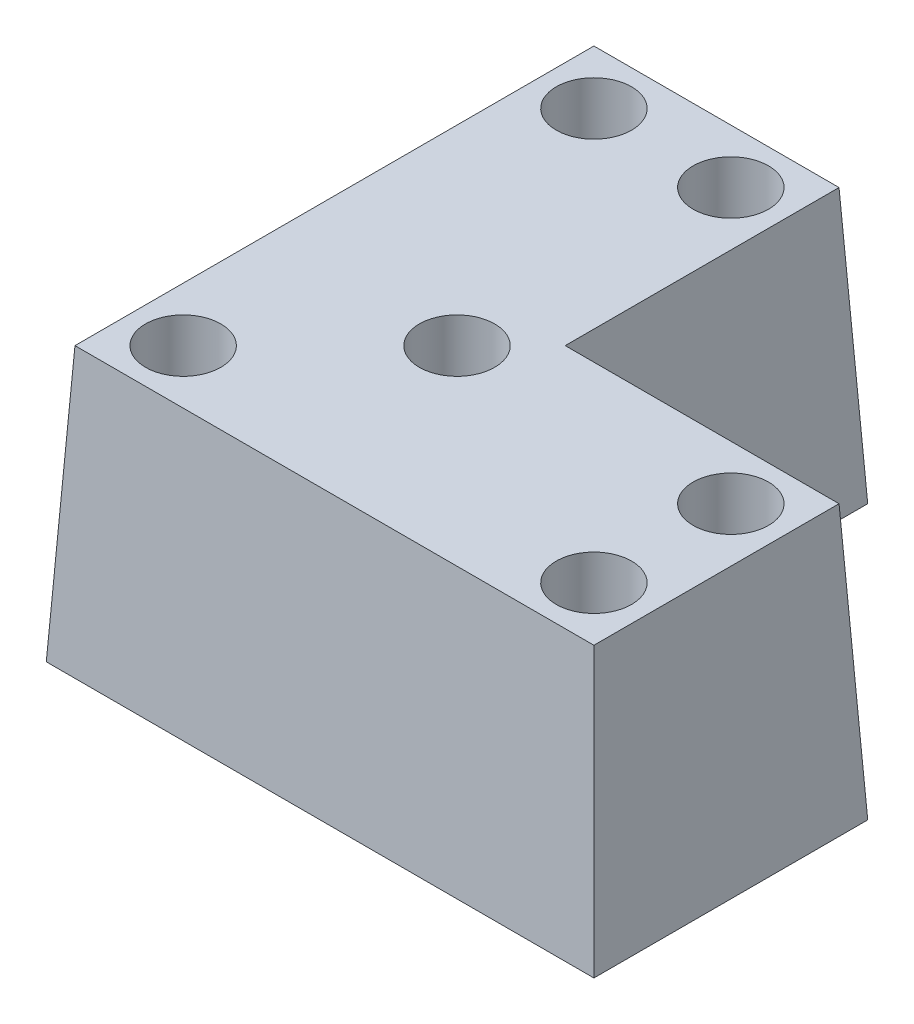
from build123d import *

# Parameters (mm, degrees)
BOSS_EXTRUDE1_DEPTH             = 40
BOSS_EXTRUDE1_TAPER             = 3
CBORE_FOR_M5_SBHCS1_D           = 5.5
CBORE_FOR_M5_SBHCS1_CBORE_D     = 11
CBORE_FOR_M5_SBHCS1_CBORE_DEPTH = 35


with BuildPart() as part:
    # Sketch1 → Boss-Extrude1 (new body)
    with BuildSketch(Plane(origin=(0, 0, 0), x_dir=(1, 0, 0), z_dir=(0, 1, 0))):
        Polygon((0, 0), (80, 0), (80, 40), (40, 40), (40, 80), (0, 80), align=None)
    extrude(amount=BOSS_EXTRUDE1_DEPTH, taper=BOSS_EXTRUDE1_TAPER)

    # CBORE for M5 SBHCS1 (through all)
    with Locations(Plane(origin=(0, 40, 0), x_dir=(1, 0, 0), z_dir=(0, 1, 0))):
        with Locations((10, 70), (30, 70), (70, 30), (70, 10), (30, 30), (10, 10)):
            CounterBoreHole(CBORE_FOR_M5_SBHCS1_D / 2, CBORE_FOR_M5_SBHCS1_CBORE_D / 2, CBORE_FOR_M5_SBHCS1_CBORE_DEPTH)


solid = part.part
